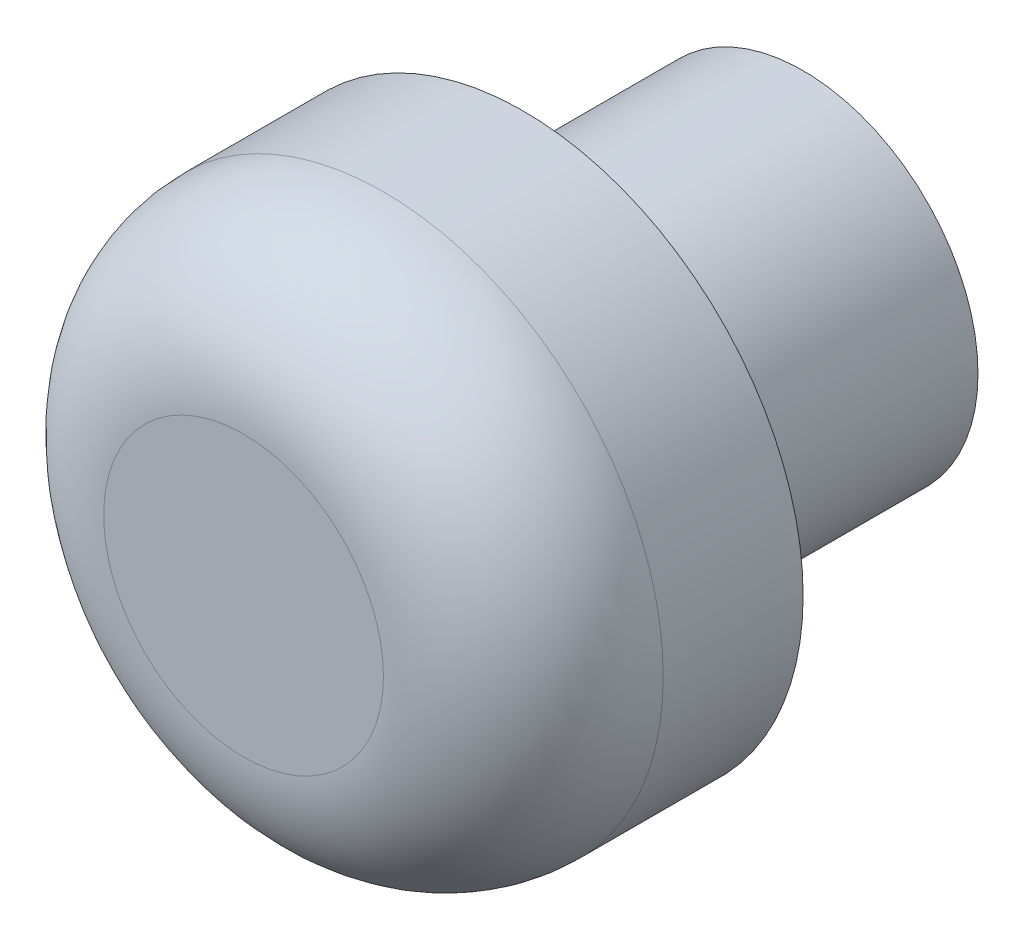
from build123d import *

# Parameters (mm, degrees)
ESBO_O1_R                = 20
RESSALTO_EXTRUS_O1_DEPTH = 20
FILETE1_R                = 10
ESBO_O3_R                = 12.5
RESSALTO_EXTRUS_O2_DEPTH = 20
ESBO_O6_R                = 3
CORTE_EXTRUS_O1_DEPTH    = 30


with BuildPart() as part:
    # Esboço1 → Ressalto-extrusão1 (new body)
    with BuildSketch(Plane.XY):
        Circle(ESBO_O1_R)
    extrude(amount=RESSALTO_EXTRUS_O1_DEPTH)

    # Filete1
    filete1_edges = [part.edges().sort_by_distance(p)[0] for p in [
        (-20, 0, 20),
    ]]
    fillet(filete1_edges, radius=FILETE1_R)

    # Esboço3 → Ressalto-extrusão2 (add)
    with BuildSketch(Plane(origin=(0, 0, 0), x_dir=(-1, 0, 0), z_dir=(0, 0, -1))):
        Circle(ESBO_O3_R)
    extrude(amount=RESSALTO_EXTRUS_O2_DEPTH)

    # Esboço6 → Corte-extrusão1 (cut)
    with BuildSketch(Plane(origin=(0, 0, -20), x_dir=(-1, 0, 0), z_dir=(0, 0, -1))):
        Circle(ESBO_O6_R)
    extrude(amount=-CORTE_EXTRUS_O1_DEPTH, mode=Mode.SUBTRACT)


solid = part.part
